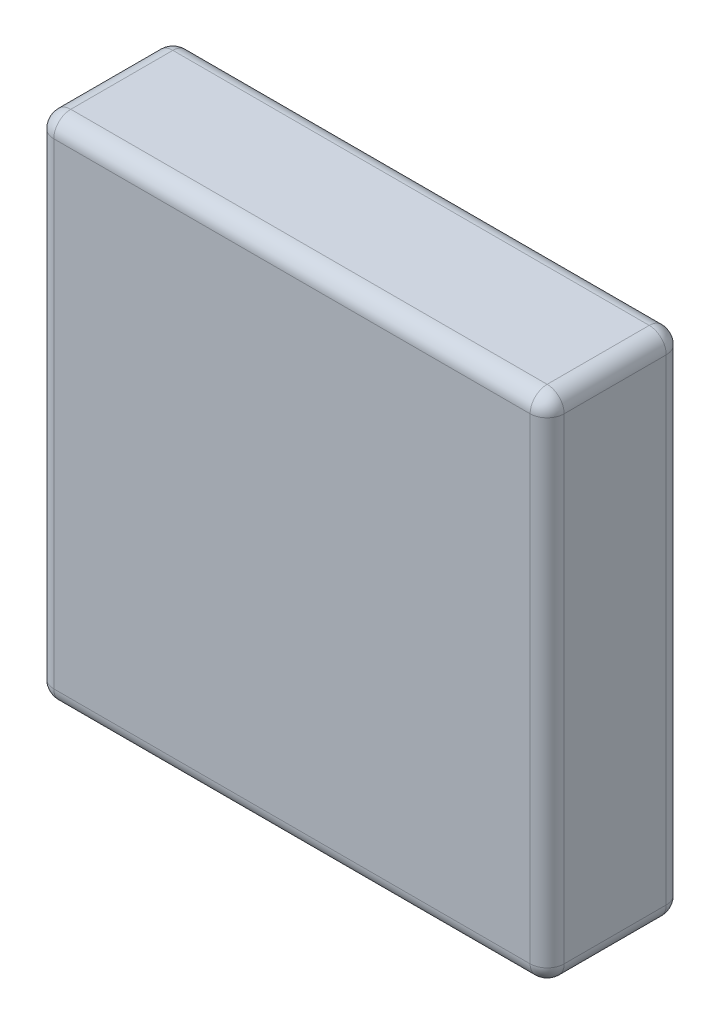
from build123d import *

# Parameters (mm, degrees)
SKETCH2_W      = 30
SKETCH2_H      = 30
EXTRUDE1_DEPTH = 8
FILLET1_R      = 1


with BuildPart() as part:
    # Sketch2 → Extrude1 (new body)
    with BuildSketch(Plane.XY):
        with Locations((15, -15)):
            Rectangle(SKETCH2_W, SKETCH2_H)
    extrude(amount=EXTRUDE1_DEPTH)

    # Fillet1
    fillet1_edges = [part.edges().sort_by_distance(p)[0] for p in [
        (30, -15, 8),
        (15, 0, 8),
        (0, -15, 8),
        (15, 0, 0),
        (30, -15, 0),
        (15, -30, 0),
        (0, -15, 0),
        (15, -30, 8),
        (0, 0, 4),
        (30, 0, 4),
        (30, -30, 4),
        (0, -30, 4),
    ]]
    fillet(fillet1_edges, radius=FILLET1_R)


solid = part.part
